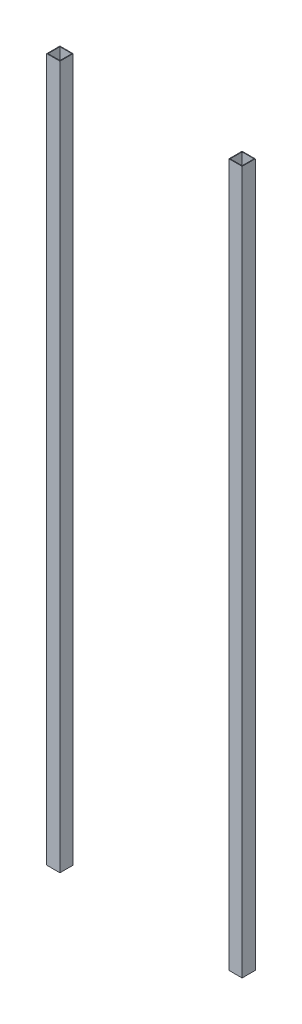
from build123d import *

# Parameters (mm, degrees)
SKETCH1_W             = 35.56
SKETCH1_H             = 35.56
SKETCH1_W_2           = 32.258
SKETCH1_H_2           = 32.258
BOSS_EXTRUDE1_DEPTH   = 1898.65
BOSS_EXTRUDE1_2_DEPTH = 1898.65


with BuildPart() as part:
    # Sketch1 → Boss-Extrude1 (new body)
    with BuildSketch(Plane(origin=(0, 0, 0), x_dir=(1, 0, 0), z_dir=(0, 1, 0))):
        with Locations((16.129, 16.129)):
            Rectangle(SKETCH1_W, SKETCH1_H)
        with Locations((16.129, 16.129)):
            Rectangle(SKETCH1_W_2, SKETCH1_H_2, mode=Mode.SUBTRACT)
    extrude(amount=BOSS_EXTRUDE1_DEPTH)


with BuildPart() as body_2:
    # Sketch1 → Boss-Extrude1 2 (new body)
    with BuildSketch(Plane(origin=(0, 0, 0), x_dir=(1, 0, 0), z_dir=(0, 1, 0))):
        with Locations((508.254, 16.129)):
            Rectangle(SKETCH1_W, SKETCH1_H)
        with Locations((508.254, 16.129)):
            Rectangle(SKETCH1_W_2, SKETCH1_H_2, mode=Mode.SUBTRACT)
    extrude(amount=BOSS_EXTRUDE1_2_DEPTH)


solid = Compound([part.part, body_2.part])
